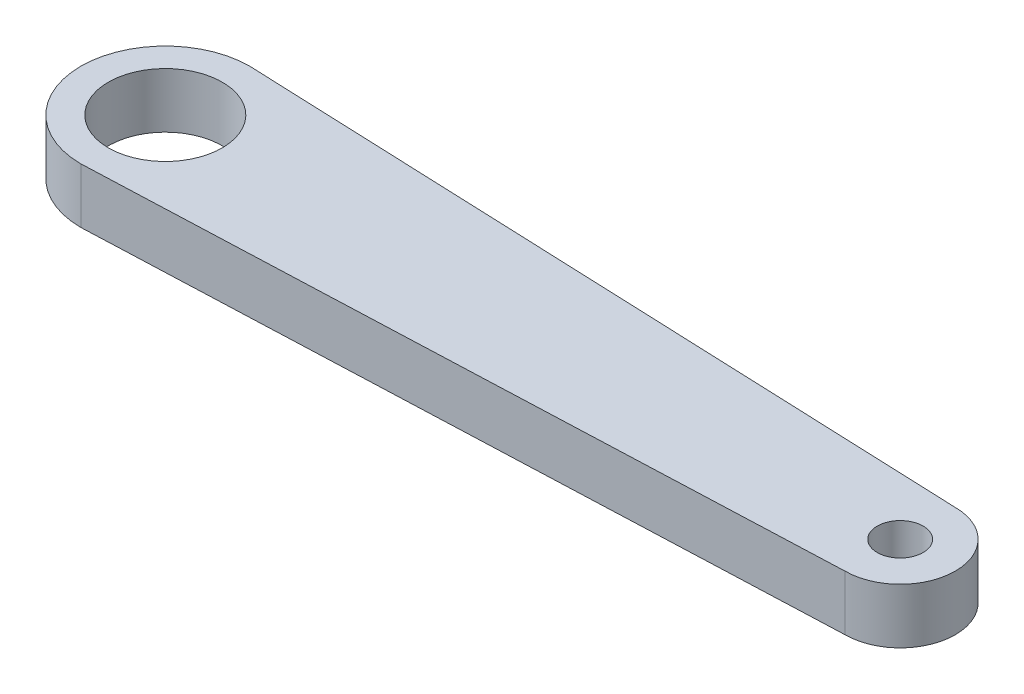
from build123d import *

# Parameters (mm, degrees)
SKETCH1_R           = 3.1
SKETCH1_R_2         = 3
SKETCH1_R_3         = 1.25
BOSS_EXTRUDE1_DEPTH = 3


with BuildPart() as part:
    # Sketch1 → Boss-Extrude1 (new body)
    with BuildSketch(Plane(origin=(0, 0, 0), x_dir=(1, 0, 0), z_dir=(0, 1, 0))):
        with BuildLine():
            Line((40, 3), (0.367412141, 4.585303514))
            ThreePointArc((0.367412141, 4.585303514), (3.380095845, 3.120088473), (4.6, 0))
            ThreePointArc((4.6, 0), (3.380095845, -3.120088473), (0.367412141, -4.585303514))
            Line((0.367412141, -4.585303514), (40, -3))
            ThreePointArc((40, -3), (37, 0), (40, 3))
        make_face()
        with BuildLine():
            Line((0.367412141, 4.585303514), (0, 4.6))
            ThreePointArc((0, 4.6), (-4.6, 0), (0, -4.6))
            Line((0, -4.6), (0.367412141, -4.585303514))
            ThreePointArc((0.367412141, -4.585303514), (3.380095845, -3.120088473), (4.6, 0))
            ThreePointArc((4.6, 0), (3.380095845, 3.120088473), (0.367412141, 4.585303514))
        make_face()
        Circle(SKETCH1_R, mode=Mode.SUBTRACT)
        with Locations((40, 0)):
            Circle(SKETCH1_R_2)
        with Locations((40, 0)):
            Circle(SKETCH1_R_3, mode=Mode.SUBTRACT)
    extrude(amount=BOSS_EXTRUDE1_DEPTH)


solid = part.part
